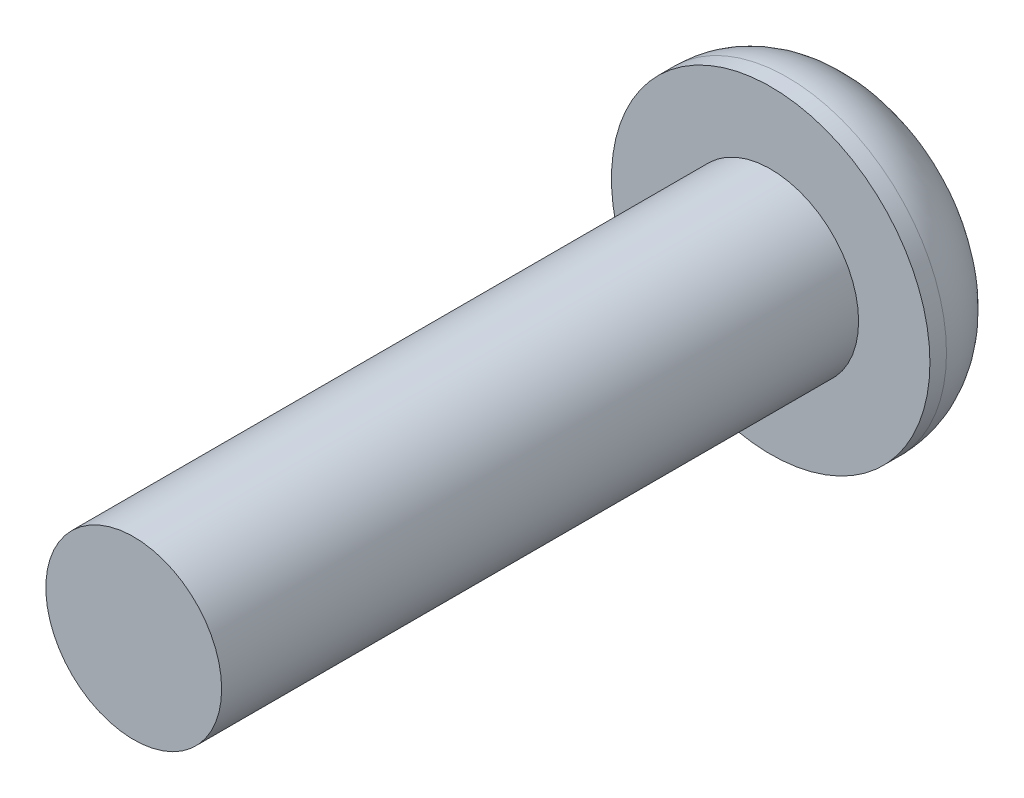
from build123d import *

# Parameters (mm, degrees)
SKETCH1_R      = 3.175
EXTRUDE1_DEPTH = 1.8542
FILLET1_R      = 1.524
SKETCH2_R      = 1.7526
EXTRUDE2_DEPTH = 12.7
EXTRUDE3_DEPTH = 1.016


with BuildPart() as part:
    # Sketch1 → Extrude1 (new body)
    with BuildSketch(Plane.XY):
        Circle(SKETCH1_R)
    extrude(amount=EXTRUDE1_DEPTH)

    # Fillet1
    fillet1_edges = [part.edges().sort_by_distance(p)[0] for p in [
        (-3.175, 0, 0),
    ]]
    fillet(fillet1_edges, radius=FILLET1_R)

    # Sketch2 → Extrude2 (add)
    with BuildSketch(Plane.XY.offset(1.8542)):
        Circle(SKETCH2_R)
    extrude(amount=EXTRUDE2_DEPTH)

    # Sketch3 → Extrude3 (cut)
    with BuildSketch(Plane(origin=(0, 0, 0), x_dir=(-1, 0, 0), z_dir=(0, 0, -1))):
        Polygon((0.59085384, 0.981566666), (-0.554634748, 1.002477769), (-1.145488588, 0.020911103), (-0.59085384, -0.981566666), (0.554634748, -1.002477769), (1.145488588, -0.020911103), align=None)
    extrude(amount=-EXTRUDE3_DEPTH, mode=Mode.SUBTRACT)


solid = part.part
